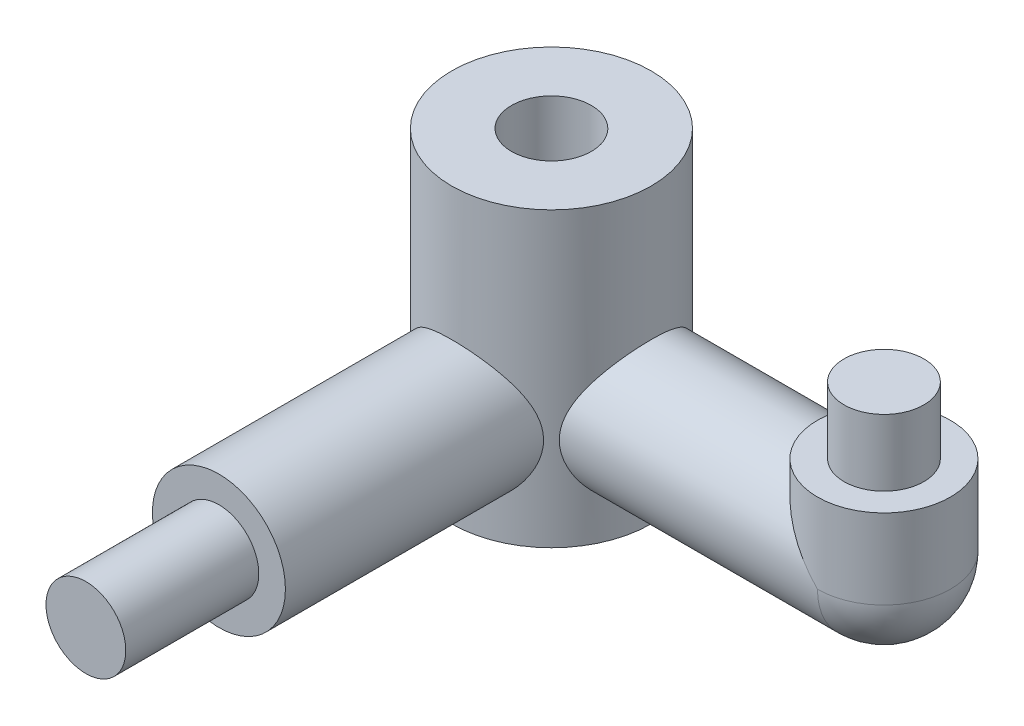
from build123d import *

# Parameters (mm, degrees)
SKETCH1_R                = 2.5
BOSS_EXTRUDE1_DEPTH      = 12.5
SKETCH2_R                = 1.5
BOSS_EXTRUDE2_DEPTH      = 5
SKETCH4_R                = 2.5
BOSS_EXTRUDE3_DEPTH      = 12.5
SKETCH5_R                = 2.5
BOSS_EXTRUDE4_DEPTH      = 3
SKETCH6_R                = 1.5
BOSS_EXTRUDE5_DEPTH      = 2.5
REVOLVE2_ANGLE           = 90
REVOLVE3_ANGLE           = 90
SKETCH18_R               = 3.75
BOSS_EXTRUDE6_DEPTH      = 7.5
BOSS_EXTRUDE6_DEPTH_BACK = 3.5
SKETCH20_R               = 1.5
CUT_EXTRUDE2_DEPTH       = 1.0000001
CUT_EXTRUDE2_DEPTH_BACK  = 12.0000001
CUT_EXTRUDE3_DEPTH       = 1.0000001
CUT_EXTRUDE3_DEPTH_BACK  = 12.0000001


with BuildPart() as part:
    # Sketch1 → Boss-Extrude1 (new body)
    with BuildSketch(Plane.XY):
        Circle(SKETCH1_R)
    boss_extrude1 = extrude(amount=BOSS_EXTRUDE1_DEPTH)

    # Sketch2 → Boss-Extrude2 (add)
    with BuildSketch(Plane(origin=(0, 0, 0), x_dir=(-1, 0, 0), z_dir=(0, 0, -1))):
        Circle(SKETCH2_R)
    boss_extrude2 = extrude(amount=BOSS_EXTRUDE2_DEPTH)

    # Sketch4 → Boss-Extrude3 (add)
    with BuildSketch(Plane(origin=(0, 0, 0), x_dir=(0, 0, -1), z_dir=(1, 0, 0))):
        with Locations((-12.5, 0)):
            Circle(SKETCH4_R)
    extrude(amount=BOSS_EXTRUDE3_DEPTH)

    # Sketch5 → Boss-Extrude4 (add)
    with BuildSketch(Plane(origin=(0, 0, 0), x_dir=(1, 0, 0), z_dir=(0, 1, 0))):
        with Locations((12.5, -12.5)):
            Circle(SKETCH5_R)
    extrude(amount=BOSS_EXTRUDE4_DEPTH)

    # Sketch6 → Boss-Extrude5 (add)
    with BuildSketch(Plane(origin=(0, 3, 0), x_dir=(1, 0, 0), z_dir=(0, 1, 0))):
        with Locations((12.5, -12.5)):
            Circle(SKETCH6_R)
    extrude(amount=BOSS_EXTRUDE5_DEPTH)

    # Sketch8 → Revolve2 (revolve)
    with BuildSketch(Plane.ZY):
        with BuildLine():
            Line((12.5, 2.5), (12.5, -2.5))
            ThreePointArc((12.5, -2.5), (15, 0), (12.5, 2.5))
        make_face()
    revolve(axis=Axis((0, 2.5, 12.5), (0, -1, 0)), revolution_arc=REVOLVE2_ANGLE)

    # Sketch16 → Revolve3 (revolve)
    with BuildSketch(Plane.XZ):
        with BuildLine():
            Line((12.5, 15), (12.5, 10))
            ThreePointArc((12.5, 10), (15, 12.5), (12.5, 15))
        make_face()
    revolve(axis=Axis((12.5, 0, 15), (0, 0, -1)), revolution_arc=REVOLVE3_ANGLE)

    # Sketch18 → Boss-Extrude6 (add, two sides)
    with BuildSketch(Plane(origin=(0, 0, 0), x_dir=(1, 0, 0), z_dir=(0, 1, 0))) as boss_extrude6_sk:
        with Locations((0, -12.5)):
            Circle(SKETCH18_R)
    extrude(amount=BOSS_EXTRUDE6_DEPTH)
    extrude(boss_extrude6_sk.sketch, amount=-BOSS_EXTRUDE6_DEPTH_BACK)

    # Mirror1: Boss-Extrude1, Boss-Extrude2 across plane
    add(boss_extrude1.mirror(Plane.XY.offset(12.5)))
    add(boss_extrude2.mirror(Plane.XY.offset(12.5)))

    # Sketch20 → Cut-Extrude2 (cut, two sides)
    with BuildSketch(Plane(origin=(0, 7.5, 0), x_dir=(1, 0, 0), z_dir=(0, 1, 0))) as cut_extrude2_sk:
        with Locations((0, -12.5)):
            Circle(SKETCH20_R)
    extrude(amount=CUT_EXTRUDE2_DEPTH, mode=Mode.SUBTRACT)
    extrude(cut_extrude2_sk.sketch, amount=-CUT_EXTRUDE2_DEPTH_BACK, mode=Mode.SUBTRACT)

    # Sketch21 → Cut-Extrude3 (cut, two sides)
    with BuildSketch(Plane(origin=(0, 7.5, 0), x_dir=(1, 0, 0), z_dir=(0, 1, 0))) as cut_extrude3_sk:
        with BuildLine():
            Line((2.653299832, -9.85), (12.281852951, 10.075018896))
            Line((12.281852951, 10.075018896), (-12.7945827, 9.436331987))
            Line((-12.7945827, 9.436331987), (-2.653299832, -9.85))
            ThreePointArc((-2.653299832, -9.85), (0, -8.75), (2.653299832, -9.85))
        make_face()
    extrude(amount=CUT_EXTRUDE3_DEPTH, mode=Mode.SUBTRACT)
    extrude(cut_extrude3_sk.sketch, amount=-CUT_EXTRUDE3_DEPTH_BACK, mode=Mode.SUBTRACT)


solid = part.part
